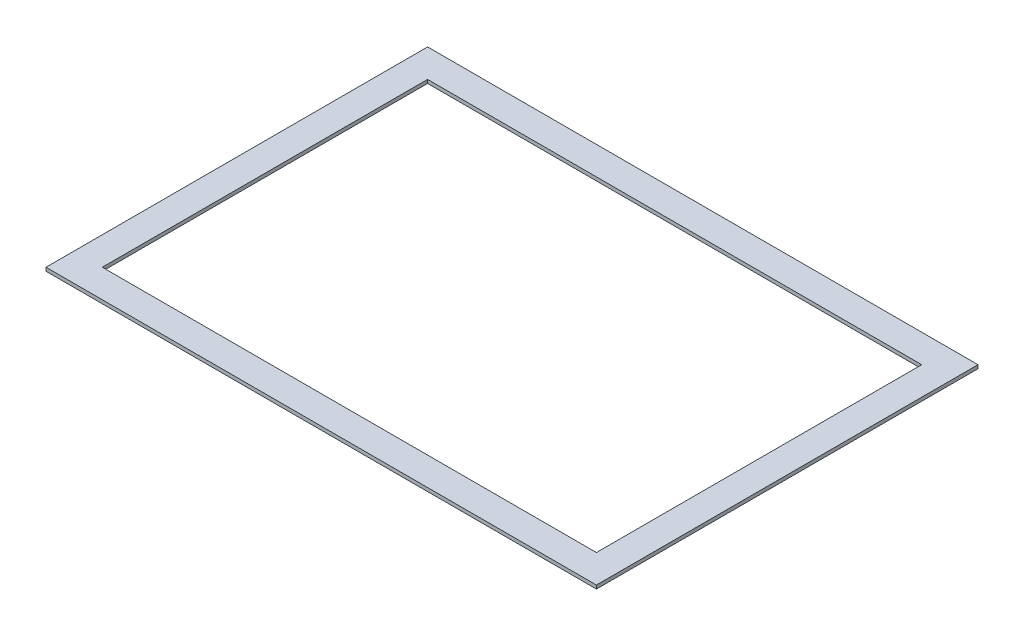
from build123d import *

# Parameters (mm, degrees)
SKETCH1_W           = 496.8875
SKETCH1_H           = 344.4875
SKETCH1_W_2         = 446.0875
SKETCH1_H_2         = 293.6875
BOSS_EXTRUDE1_DEPTH = 3.175


with BuildPart() as part:
    # Sketch1 → Boss-Extrude1 (new body)
    with BuildSketch(Plane(origin=(0, 0, 0), x_dir=(1, 0, 0), z_dir=(0, 1, 0))):
        Rectangle(SKETCH1_W, SKETCH1_H)
        Rectangle(SKETCH1_W_2, SKETCH1_H_2, mode=Mode.SUBTRACT)
    extrude(amount=BOSS_EXTRUDE1_DEPTH)


solid = part.part
